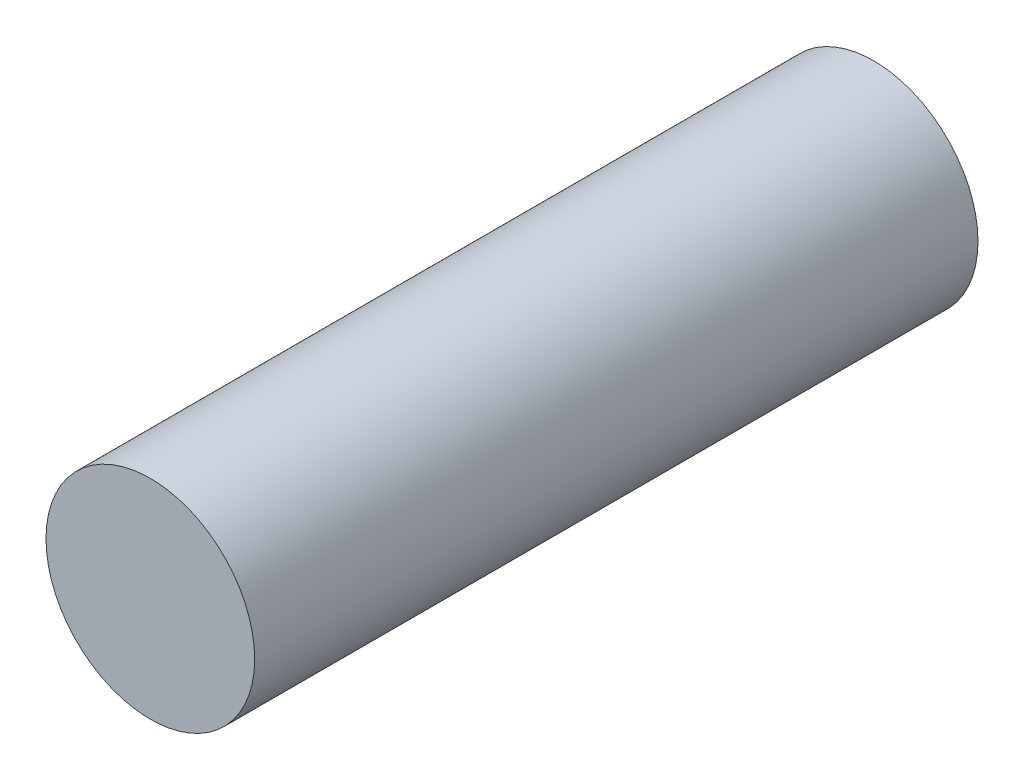
from build123d import *

# Parameters (mm, degrees)
SKETCH_1_R      = 7.025
EXTRUDE_1_DEPTH = 48.7


with BuildPart() as part:
    # Эскиз1 → Бобышка-Вытянуть1 (new body)
    with BuildSketch(Plane.XY):
        Circle(SKETCH_1_R)
    extrude(amount=EXTRUDE_1_DEPTH)


solid = part.part
